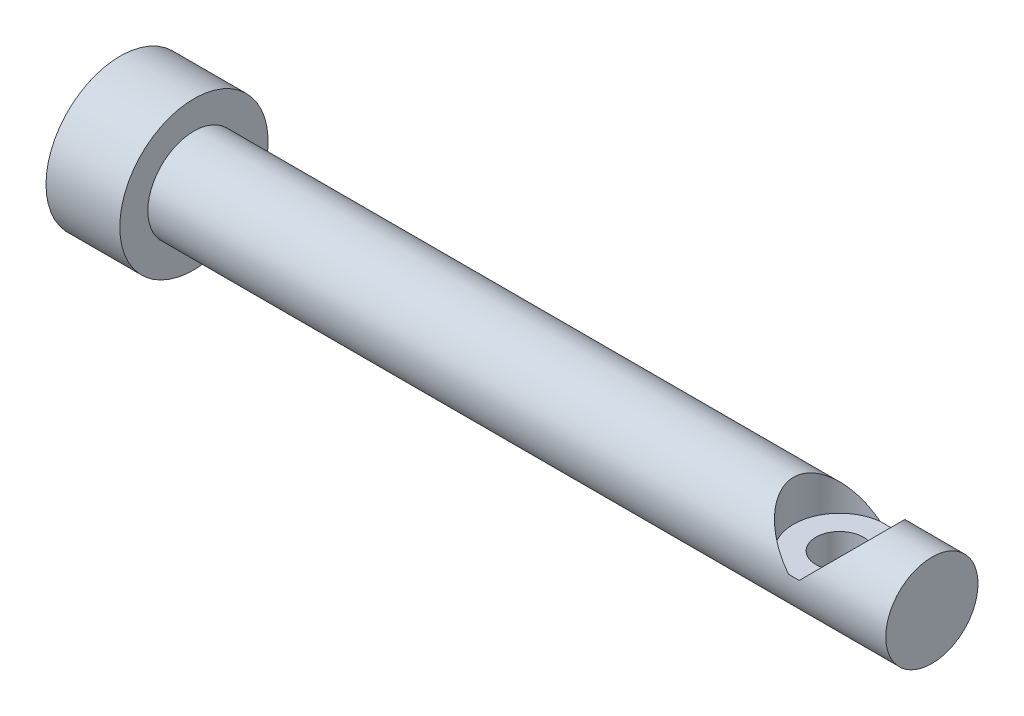
from build123d import *

# Parameters (mm, degrees)
CBORE_FOR_6_SOCKET_HEAD_CAP_SCREW1_D           = 4.0894
CBORE_FOR_6_SOCKET_HEAD_CAP_SCREW1_CBORE_D     = 7.9375
CBORE_FOR_6_SOCKET_HEAD_CAP_SCREW1_CBORE_DEPTH = 3.5052
SKETCH7_R                                      = 3.96875
BOSS_EXTRUDE1_DEPTH                            = 3.175


with BuildPart() as part:
    # Sketch1 → Revolve1 (revolve)
    with BuildSketch(Plane.XY):
        Polygon((-46.0375, 40.64), (-46.0375, 47.02175), (-39.6875, 47.02175), (-39.6875, 44.60875), (20.6375, 44.60875), (20.6375, 40.64), align=None)
    revolve(axis=Axis((-56.202964931, 40.64, 0), (1, 0, 0)))

    # CBORE for #6 Socket Head Cap Screw1 (through all)
    with Locations(Plane(origin=(0, 44.60875, 0), x_dir=(1, 0, 0), z_dir=(0, 1, 0))):
        with Locations((15.875, 0)):
            CounterBoreHole(CBORE_FOR_6_SOCKET_HEAD_CAP_SCREW1_D / 2, CBORE_FOR_6_SOCKET_HEAD_CAP_SCREW1_CBORE_D / 2, CBORE_FOR_6_SOCKET_HEAD_CAP_SCREW1_CBORE_DEPTH)

    # Sketch7 → Boss-Extrude1 (add)
    with BuildSketch(Plane(origin=(20.6375, 0, 0), x_dir=(0, 0, -1), z_dir=(1, 0, 0))):
        with Locations((0, 40.64)):
            Circle(SKETCH7_R)
    extrude(amount=BOSS_EXTRUDE1_DEPTH)


solid = part.part
